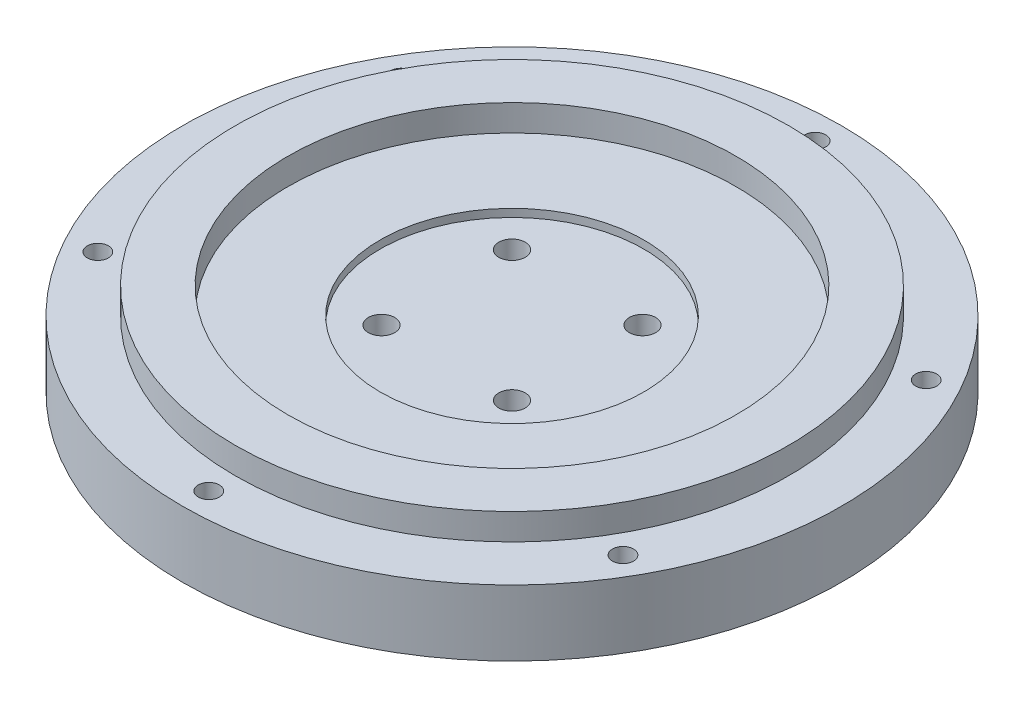
from build123d import *

# Parameters (mm, degrees)
SKETCH1_R           = 125
SKETCH1_R_2         = 4
BOSS_EXTRUDE1_DEPTH = 25
SKETCH4_R           = 9
CUT_EXTRUDE1_DEPTH  = 10
SKETCH6_R           = 5
CUT_EXTRUDE2_DEPTH  = 15
SKETCH7_R           = 50
CUT_EXTRUDE3_DEPTH  = 3
SKETCH8_R           = 105
SKETCH8_R_2         = 85
BOSS_EXTRUDE2_DEPTH = 10


with BuildPart() as part:
    # Sketch1 → Boss-Extrude1 (new body)
    with BuildSketch(Plane(origin=(0, 0, 0), x_dir=(1, 0, 0), z_dir=(0, 1, 0))):
        Circle(SKETCH1_R)
        with Locations((0, 115)):
            Circle(SKETCH1_R_2, mode=Mode.SUBTRACT)
        with Locations((99.592921435, 57.5)):
            Circle(SKETCH1_R_2, mode=Mode.SUBTRACT)
        with Locations((99.592921435, -57.5)):
            Circle(SKETCH1_R_2, mode=Mode.SUBTRACT)
        with Locations((0, -115)):
            Circle(SKETCH1_R_2, mode=Mode.SUBTRACT)
        with Locations((-99.592921435, -57.5)):
            Circle(SKETCH1_R_2, mode=Mode.SUBTRACT)
        with Locations((-99.592921435, 57.5)):
            Circle(SKETCH1_R_2, mode=Mode.SUBTRACT)
    extrude(amount=BOSS_EXTRUDE1_DEPTH)

    # Sketch4 → Cut-Extrude1 (cut)
    with BuildSketch(Plane.XZ):
        with Locations((-24.748737342, 24.748737342)):
            Circle(SKETCH4_R)
        with Locations((24.748737342, 24.748737342)):
            Circle(SKETCH4_R)
        with Locations((24.748737342, -24.748737342)):
            Circle(SKETCH4_R)
        with Locations((-24.748737342, -24.748737342)):
            Circle(SKETCH4_R)
    extrude(amount=-CUT_EXTRUDE1_DEPTH, mode=Mode.SUBTRACT)

    # Sketch6 → Cut-Extrude2 (cut)
    with BuildSketch(Plane.XZ.offset(-10)):
        with Locations((-24.748737342, 24.748737342)):
            Circle(SKETCH6_R)
        with Locations((24.748737342, 24.748737342)):
            Circle(SKETCH6_R)
        with Locations((24.748737342, -24.748737342)):
            Circle(SKETCH6_R)
        with Locations((-24.748737342, -24.748737342)):
            Circle(SKETCH6_R)
    extrude(amount=-CUT_EXTRUDE2_DEPTH, mode=Mode.SUBTRACT)

    # Sketch7 → Cut-Extrude3 (cut)
    with BuildSketch(Plane(origin=(0, 25, 0), x_dir=(1, 0, 0), z_dir=(0, 1, 0))):
        Circle(SKETCH7_R)
    extrude(amount=-CUT_EXTRUDE3_DEPTH, mode=Mode.SUBTRACT)

    # Sketch8 → Boss-Extrude2 (add)
    with BuildSketch(Plane(origin=(0, 25, 0), x_dir=(1, 0, 0), z_dir=(0, 1, 0))):
        Circle(SKETCH8_R)
        Circle(SKETCH8_R_2, mode=Mode.SUBTRACT)
    extrude(amount=BOSS_EXTRUDE2_DEPTH)


solid = part.part
